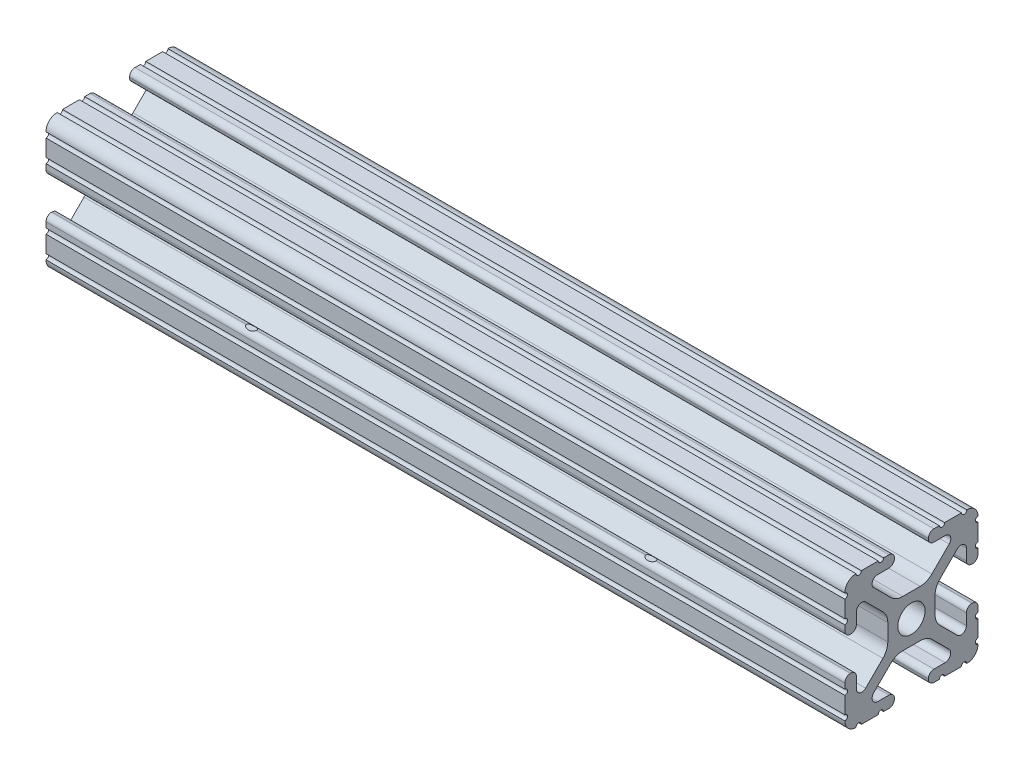
from build123d import *

# Parameters (mm, degrees)
SKETCH1_R               = 2.6035
BOSS_EXTRUDE1_DEPTH     = 152.4
SKETCH2_R               = 3.3782
CUT_EXTRUDE1_DEPTH      = 13.7
CUT_EXTRUDE1_DEPTH_BACK = 13.7


with BuildPart() as part:
    # Sketch1 → Boss-Extrude1 (new body)
    with BuildSketch(Plane(origin=(0, 0, 0), x_dir=(0, 0, -1), z_dir=(1, 0, 0))):
        with BuildLine():
            Line((6.333126718, -12.7), (9.550443118, -12.7))
            ThreePointArc((9.550443118, -12.7), (10.058366869, -12.192000006), (10.566443095, -12.699847501))
            ThreePointArc((10.566443095, -12.699847501), (12.082537762, -12.08250727), (12.699846982, -10.566399977))
            ThreePointArc((12.699846982, -10.566399977), (12.192000006, -10.058323491), (12.7, -9.5504))
            Line((12.7, -9.5504), (12.7, -6.3330836))
            ThreePointArc((12.7, -6.3330836), (12.192, -5.8250836), (12.7, -5.3170836))
            Line((12.7, -5.3170836), (12.7, -4.287469289))
            ThreePointArc((12.7, -4.287469289), (12.39275138, -3.545705502), (11.650987593, -3.238456882))
            Line((11.650987593, -3.238456882), (11.539212407, -3.238456882))
            ThreePointArc((11.539212407, -3.238456882), (10.79744862, -3.545705502), (10.4902, -4.287469289))
            Line((10.4902, -4.287469289), (10.4902, -6.402089023))
            ThreePointArc((10.4902, -6.402089023), (9.856505071, -7.351067942), (8.737131347, -7.129408934))
            Line((8.737131347, -7.129408934), (5.441005833, -3.840816462))
            ThreePointArc((5.441005833, -3.840816462), (4.750877967, -2.809883091), (4.5085, -1.593185507))
            Line((4.5085, -1.593185507), (4.5085, 1.593185507))
            ThreePointArc((4.5085, 1.593185507), (4.750877967, 2.809883091), (5.441005833, 3.840816462))
            Line((5.441005833, 3.840816462), (8.737131347, 7.129408934))
            ThreePointArc((8.737131347, 7.129408934), (9.856505071, 7.351067942), (10.4902, 6.402089023))
            Line((10.4902, 6.402089023), (10.4902, 4.287469289))
            ThreePointArc((10.4902, 4.287469289), (10.79744862, 3.545705502), (11.539212407, 3.238456882))
            Line((11.539212407, 3.238456882), (11.650987593, 3.238456882))
            ThreePointArc((11.650987593, 3.238456882), (12.39275138, 3.545705502), (12.7, 4.287469289))
            Line((12.7, 4.287469289), (12.7, 5.3170836))
            ThreePointArc((12.7, 5.3170836), (12.192, 5.8250836), (12.7, 6.3330836))
            Line((12.7, 6.3330836), (12.7, 9.5504))
            ThreePointArc((12.7, 9.5504), (12.192000006, 10.058323491), (12.699846982, 10.566399977))
            ThreePointArc((12.699846982, 10.566399977), (12.082537762, 12.08250727), (10.566443095, 12.699847501))
            ThreePointArc((10.566443095, 12.699847501), (10.058366869, 12.192000006), (9.550443118, 12.7))
            Line((9.550443118, 12.7), (6.333126718, 12.7))
            ThreePointArc((6.333126718, 12.7), (5.825126718, 12.192), (5.317126718, 12.7))
            Line((5.317126718, 12.7), (4.287512407, 12.7))
            ThreePointArc((4.287512407, 12.7), (3.54574862, 12.39275138), (3.2385, 11.650987593))
            Line((3.2385, 11.650987593), (3.2385, 11.539212407))
            ThreePointArc((3.2385, 11.539212407), (3.54574862, 10.79744862), (4.287512407, 10.4902))
            Line((4.287512407, 10.4902), (6.476788598, 10.4902))
            ThreePointArc((6.476788598, 10.4902), (7.432222385, 9.85140422), (7.207036008, 8.724370562))
            Line((7.207036008, 8.724370562), (3.898272566, 5.423169045))
            ThreePointArc((3.898272566, 5.423169045), (2.869120213, 4.736787962), (1.655778399, 4.4958))
            Line((1.655778399, 4.4958), (-1.655778399, 4.4958))
            ThreePointArc((-1.655778399, 4.4958), (-2.869120213, 4.736787962), (-3.898272566, 5.423169045))
            Line((-3.898272566, 5.423169045), (-7.207036008, 8.724370562))
            ThreePointArc((-7.207036008, 8.724370562), (-7.432222385, 9.85140422), (-6.476788598, 10.4902))
            Line((-6.476788598, 10.4902), (-4.287512407, 10.4902))
            ThreePointArc((-4.287512407, 10.4902), (-3.54574862, 10.79744862), (-3.2385, 11.539212407))
            Line((-3.2385, 11.539212407), (-3.2385, 11.650987593))
            ThreePointArc((-3.2385, 11.650987593), (-3.54574862, 12.39275138), (-4.287512407, 12.7))
            Line((-4.287512407, 12.7), (-5.317126718, 12.7))
            ThreePointArc((-5.317126718, 12.7), (-5.825126718, 12.192), (-6.333126718, 12.7))
            Line((-6.333126718, 12.7), (-9.550443118, 12.7))
            ThreePointArc((-9.550443118, 12.7), (-10.058366869, 12.192000006), (-10.566443095, 12.699847501))
            ThreePointArc((-10.566443095, 12.699847501), (-12.082537762, 12.08250727), (-12.699846982, 10.566399977))
            ThreePointArc((-12.699846982, 10.566399977), (-12.192000006, 10.058323491), (-12.7, 9.5504))
            Line((-12.7, 9.5504), (-12.7, 6.3330836))
            ThreePointArc((-12.7, 6.3330836), (-12.192, 5.8250836), (-12.7, 5.3170836))
            Line((-12.7, 5.3170836), (-12.7, 4.287469289))
            ThreePointArc((-12.7, 4.287469289), (-12.39275138, 3.545705502), (-11.650987593, 3.238456882))
            Line((-11.650987593, 3.238456882), (-11.539212407, 3.238456882))
            ThreePointArc((-11.539212407, 3.238456882), (-10.79744862, 3.545705502), (-10.4902, 4.287469289))
            Line((-10.4902, 4.287469289), (-10.4902, 6.402089023))
            ThreePointArc((-10.4902, 6.402089023), (-9.856505071, 7.351067942), (-8.737131347, 7.129408934))
            Line((-8.737131347, 7.129408934), (-5.441005833, 3.840816462))
            ThreePointArc((-5.441005833, 3.840816462), (-4.750877967, 2.809883091), (-4.5085, 1.593185507))
            Line((-4.5085, 1.593185507), (-4.5085, -1.593185507))
            ThreePointArc((-4.5085, -1.593185507), (-4.750877967, -2.809883091), (-5.441005833, -3.840816462))
            Line((-5.441005833, -3.840816462), (-8.737131347, -7.129408934))
            ThreePointArc((-8.737131347, -7.129408934), (-9.856505071, -7.351067942), (-10.4902, -6.402089023))
            Line((-10.4902, -6.402089023), (-10.4902, -4.287469289))
            ThreePointArc((-10.4902, -4.287469289), (-10.79744862, -3.545705502), (-11.539212407, -3.238456882))
            Line((-11.539212407, -3.238456882), (-11.650987593, -3.238456882))
            ThreePointArc((-11.650987593, -3.238456882), (-12.39275138, -3.545705502), (-12.7, -4.287469289))
            Line((-12.7, -4.287469289), (-12.7, -5.3170836))
            ThreePointArc((-12.7, -5.3170836), (-12.192, -5.8250836), (-12.7, -6.3330836))
            Line((-12.7, -6.3330836), (-12.7, -9.5504))
            ThreePointArc((-12.7, -9.5504), (-12.192000006, -10.058323491), (-12.699846982, -10.566399977))
            ThreePointArc((-12.699846982, -10.566399977), (-12.082537762, -12.08250727), (-10.566443095, -12.699847501))
            ThreePointArc((-10.566443095, -12.699847501), (-10.058366869, -12.192000006), (-9.550443118, -12.7))
            Line((-9.550443118, -12.7), (-6.333126718, -12.7))
            ThreePointArc((-6.333126718, -12.7), (-5.825126718, -12.192), (-5.317126718, -12.7))
            Line((-5.317126718, -12.7), (-4.287512407, -12.7))
            ThreePointArc((-4.287512407, -12.7), (-3.54574862, -12.39275138), (-3.2385, -11.650987593))
            Line((-3.2385, -11.650987593), (-3.2385, -11.539212407))
            ThreePointArc((-3.2385, -11.539212407), (-3.54574862, -10.79744862), (-4.287512407, -10.4902))
            Line((-4.287512407, -10.4902), (-6.416408329, -10.4902))
            ThreePointArc((-6.416408329, -10.4902), (-7.41473083, -9.822813117), (-7.179650497, -8.645192506))
            Line((-7.179650497, -8.645192506), (-3.952270251, -5.423690499))
            ThreePointArc((-3.952270251, -5.423690499), (-2.922936451, -4.736929036), (-1.709253557, -4.4958))
            Line((-1.709253557, -4.4958), (1.709253557, -4.4958))
            ThreePointArc((1.709253557, -4.4958), (2.922936451, -4.736929036), (3.952270251, -5.423690499))
            Line((3.952270251, -5.423690499), (7.179650497, -8.645192506))
            ThreePointArc((7.179650497, -8.645192506), (7.41473083, -9.822813117), (6.416408329, -10.4902))
            Line((6.416408329, -10.4902), (4.287512407, -10.4902))
            ThreePointArc((4.287512407, -10.4902), (3.54574862, -10.79744862), (3.2385, -11.539212407))
            Line((3.2385, -11.539212407), (3.2385, -11.650987593))
            ThreePointArc((3.2385, -11.650987593), (3.54574862, -12.39275138), (4.287512407, -12.7))
            Line((4.287512407, -12.7), (5.317126718, -12.7))
            ThreePointArc((5.317126718, -12.7), (5.825126718, -12.192), (6.333126718, -12.7))
        make_face()
        Circle(SKETCH1_R, mode=Mode.SUBTRACT)
    extrude(amount=BOSS_EXTRUDE1_DEPTH)

    # Sketch2 → Cut-Extrude1 (cut, two sides)
    with BuildSketch(Plane.XY) as cut_extrude1_sk:
        with Locations((114.3, 0)):
            Circle(SKETCH2_R)
        with Locations((38.1, 0)):
            Circle(SKETCH2_R)
    extrude(amount=CUT_EXTRUDE1_DEPTH, mode=Mode.SUBTRACT)
    extrude(cut_extrude1_sk.sketch, amount=-CUT_EXTRUDE1_DEPTH_BACK, mode=Mode.SUBTRACT)


solid = part.part
